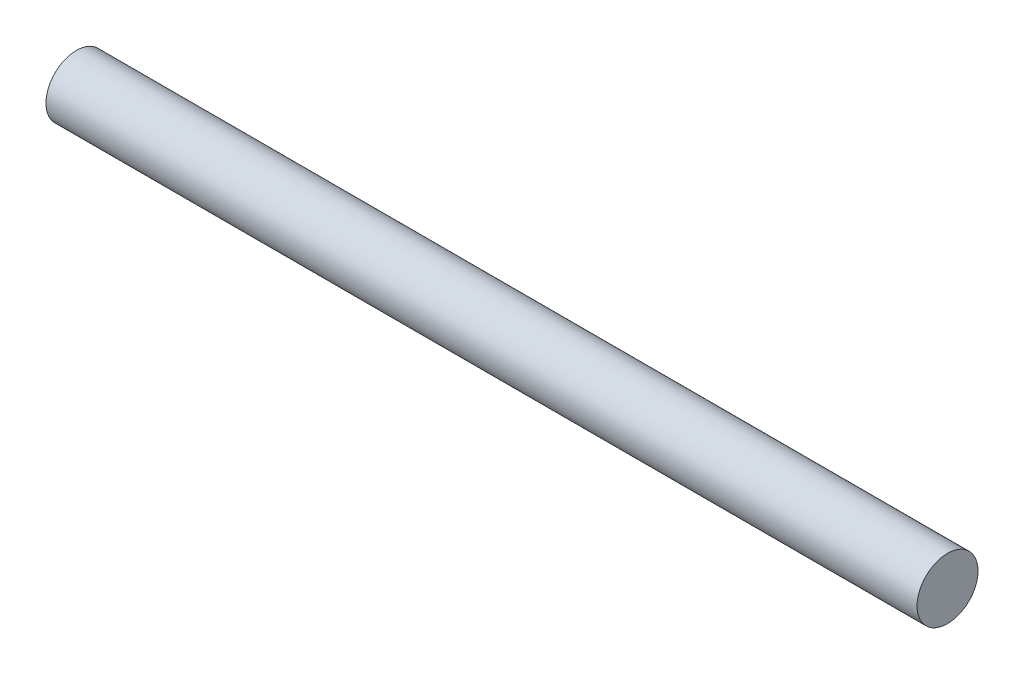
from build123d import *

# Parameters (mm, degrees)
SKETCH1_R           = 17.5
BOSS_EXTRUDE1_DEPTH = 250


with BuildPart() as part:
    # Sketch1 → Boss-Extrude1 (new body, symmetric)
    with BuildSketch(Plane(origin=(0, 0, 0), x_dir=(0, 0, -1), z_dir=(1, 0, 0))):
        Circle(SKETCH1_R)
    extrude(amount=BOSS_EXTRUDE1_DEPTH, both=True)


solid = part.part
